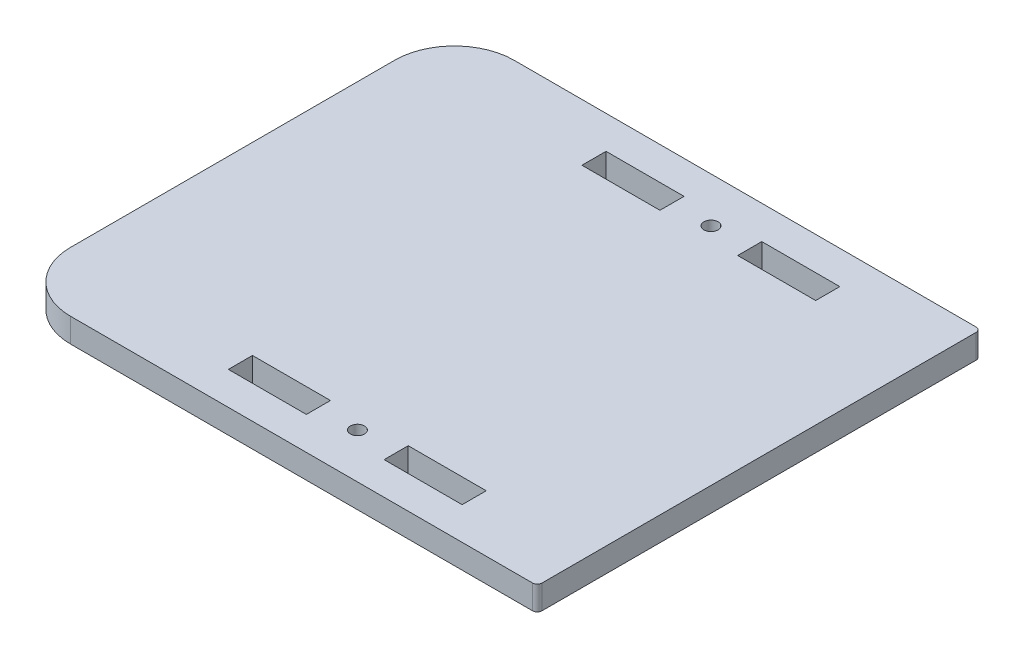
from build123d import *

# Parameters (mm, degrees)
SKETCH2_R                   = 1.5
SKETCH2_W                   = 16.6
SKETCH2_H                   = 5.13
BOSS_EXTRUDE1_DEPTH         = 5.13
F_1_2_CLEARANCE_HOLE1_D     = 13.89126
F_1_2_CLEARANCE_HOLE1_DEPTH = 5.13


with BuildPart() as part:
    # Sketch2 → Boss-Extrude1 (new body)
    with BuildSketch(Plane(origin=(0, 0, 0), x_dir=(1, 0, 0), z_dir=(0, 1, 0))):
        with BuildLine():
            Line((-210.314103066, 2127.521742865), (-210.314103066, 2196.481742865))
            ThreePointArc((-210.314103066, 2196.481742865), (-206.594359187, 2205.461998986), (-197.614103066, 2209.181742865))
            Line((-197.614103066, 2209.181742865), (-99.314103066, 2209.181742865))
            ThreePointArc((-99.314103066, 2209.181742865), (-98.606996285, 2208.888849646), (-98.314103066, 2208.181742865))
            Line((-98.314103066, 2208.181742865), (-98.314103066, 2115.821742865))
            ThreePointArc((-98.314103066, 2115.821742865), (-98.606996285, 2115.114636084), (-99.314103066, 2114.821742865))
            Line((-99.314103066, 2114.821742865), (-197.614103066, 2114.821742865))
            ThreePointArc((-197.614103066, 2114.821742865), (-206.594359187, 2118.541486744), (-210.314103066, 2127.521742865))
        make_face()
        with Locations((-146.144103066, 2199.616742865)):
            Circle(SKETCH2_R, mode=Mode.SUBTRACT)
        with Locations((-146.144103066, 2124.386742865)):
            Circle(SKETCH2_R, mode=Mode.SUBTRACT)
        with Locations((-129.544103066, 2124.326494276)):
            Rectangle(SKETCH2_W, SKETCH2_H, mode=Mode.SUBTRACT)
        with Locations((-162.744103066, 2124.386742865)):
            Rectangle(SKETCH2_W, SKETCH2_H, mode=Mode.SUBTRACT)
        with Locations((-162.744103066, 2199.615933693)):
            Rectangle(SKETCH2_W, SKETCH2_H, mode=Mode.SUBTRACT)
        with Locations((-129.544103066, 2199.555685104)):
            Rectangle(SKETCH2_W, SKETCH2_H, mode=Mode.SUBTRACT)
    extrude(amount=BOSS_EXTRUDE1_DEPTH)

    # 1/2 Clearance Hole1
    with Locations(Plane(origin=(0, 5.13, 0), x_dir=(-1, 0, 0), z_dir=(0, 1, 0))):
        with Locations((-8.273522926, -2159.461742865)):
            Hole(F_1_2_CLEARANCE_HOLE1_D / 2, depth=F_1_2_CLEARANCE_HOLE1_DEPTH)


solid = part.part
